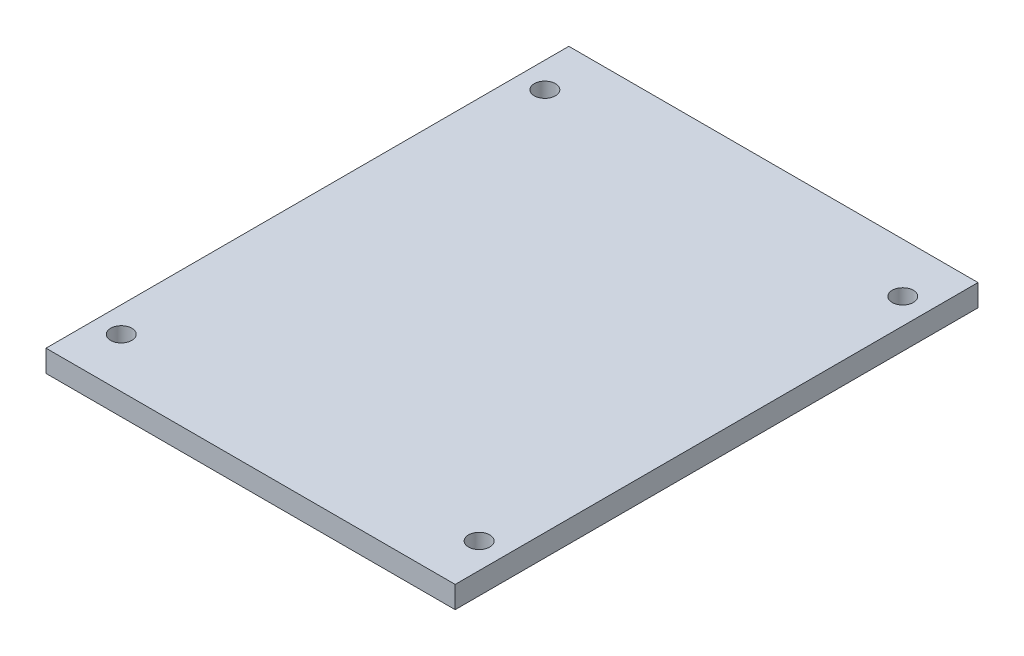
from build123d import *

# Parameters (mm, degrees)
SKETCH1_W           = 56.02
SKETCH1_H           = 71.58
SKETCH1_R           = 1.45
BOSS_EXTRUDE1_DEPTH = 3


with BuildPart() as part:
    # Sketch1 → Boss-Extrude1 (new body)
    with BuildSketch(Plane(origin=(0, 0, 0), x_dir=(1, 0, 0), z_dir=(0, 1, 0))):
        Rectangle(SKETCH1_W, SKETCH1_H)
        with Locations((-24.5, 29)):
            Circle(SKETCH1_R, mode=Mode.SUBTRACT)
        with Locations((-24.5, -29)):
            Circle(SKETCH1_R, mode=Mode.SUBTRACT)
        with Locations((24.5, -29)):
            Circle(SKETCH1_R, mode=Mode.SUBTRACT)
        with Locations((24.5, 29)):
            Circle(SKETCH1_R, mode=Mode.SUBTRACT)
    extrude(amount=BOSS_EXTRUDE1_DEPTH)


solid = part.part
